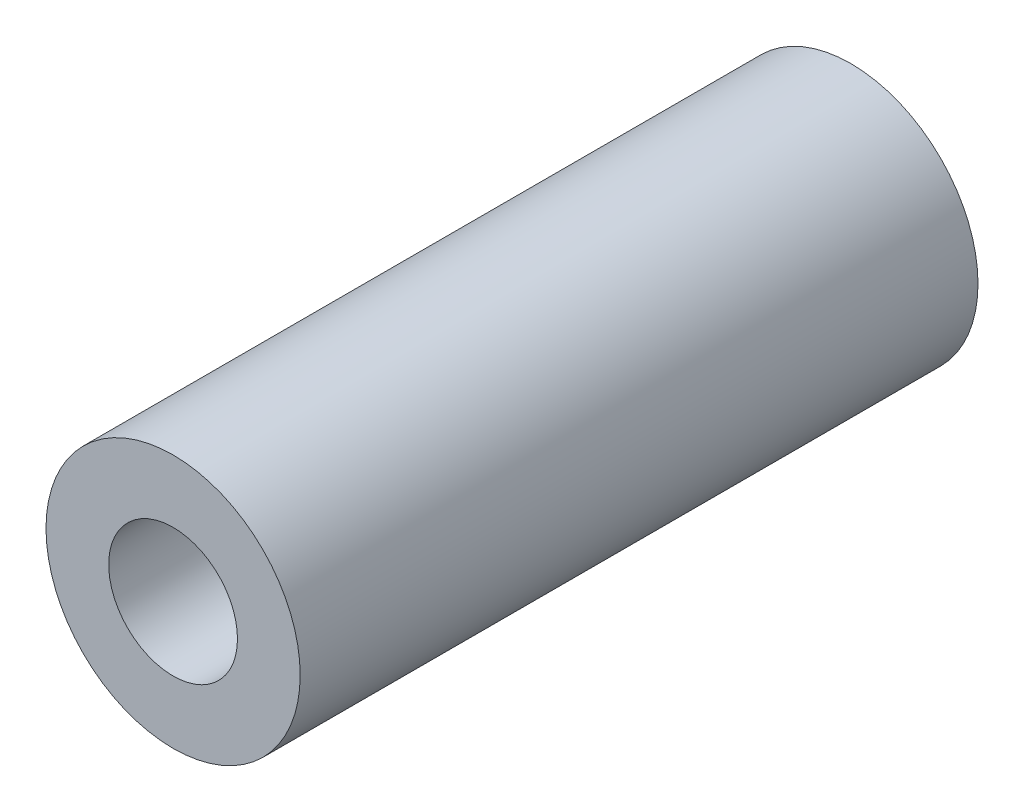
from build123d import *

# Parameters (mm, degrees)
IZIM1_R                     = 9.525
IZIM1_R_2                   = 4.826
Y_KSEKLIK_EKSTR_ZYON1_DEPTH = 50.8


with BuildPart() as part:
    # Çizim1 → Yükseklik-Ekstrüzyon1 (new body)
    with BuildSketch(Plane.XY):
        Circle(IZIM1_R)
        Circle(IZIM1_R_2, mode=Mode.SUBTRACT)
    extrude(amount=Y_KSEKLIK_EKSTR_ZYON1_DEPTH)


solid = part.part
